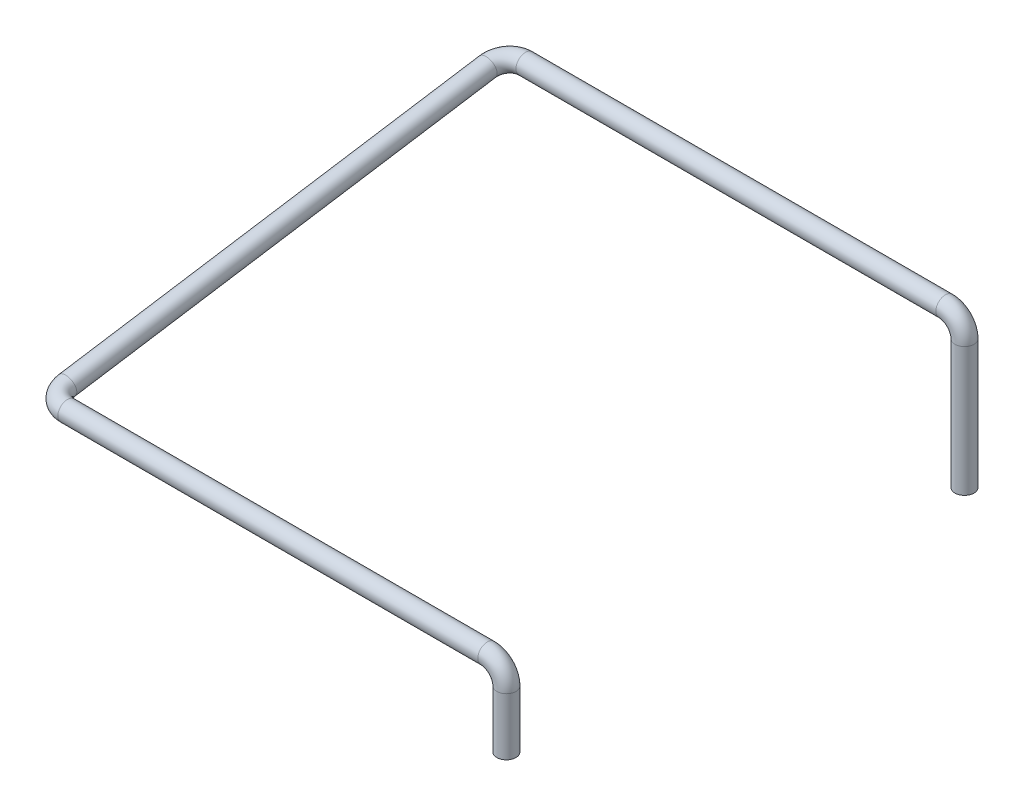
from build123d import *

# Parameters (mm, degrees)
SKETCH4_R = 0.5
SKETCH5_R = 0.5
SKETCH6_R = 0.5


with BuildPart() as part:
    # Sweep1: sweep along a path in Sketch1
    with BuildLine(Plane.XY) as sweep1_path:
        Line((0, 0), (22, 0))
        ThreePointArc((22, 0), (22.707106781, -0.292893219), (23, -1))
        Line((23, -1), (23, -4))
    # Sketch4 → Sweep1 (sweep)
    with BuildSketch(Plane(origin=(0, 0, 0), x_dir=(0, 0, -1), z_dir=(1, 0, 0))):
        Circle(SKETCH4_R)
    sweep(path=sweep1_path.line)

    # Sweep2: sweep along a path in Sketch3
    with BuildLine(Plane(origin=(0, 0, 0), x_dir=(-1, 0, 0), z_dir=(0, 0.988012034, 0.15437688))) as sweep2_path:
        ThreePointArc((0, -24.291202111), (0.707106781, -23.998308892), (1, -23.291202111))
        Line((1, -23.291202111), (1, -1))
        ThreePointArc((1, -1), (0.707106781, -0.292893219), (0, 0))
    # Sketch5 → Sweep2 (sweep)
    with BuildSketch(Plane.ZY):
        Circle(SKETCH5_R)
    sweep(path=sweep2_path.line)

    # Sweep3: sweep along a path in Sketch2
    with BuildLine(Plane.XY.offset(-24)) as sweep3_path:
        Line((0, 3.75), (22, 3.75))
        ThreePointArc((22, 3.75), (22.707106781, 3.457106781), (23, 2.75))
        Line((23, 2.75), (23, -4))
    # Sketch6 → Sweep3 (sweep)
    with BuildSketch(Plane(origin=(0, 0, 0), x_dir=(0, 0, -1), z_dir=(1, 0, 0))):
        with Locations((24, 3.75)):
            Circle(SKETCH6_R)
    sweep(path=sweep3_path.line)


solid = part.part
